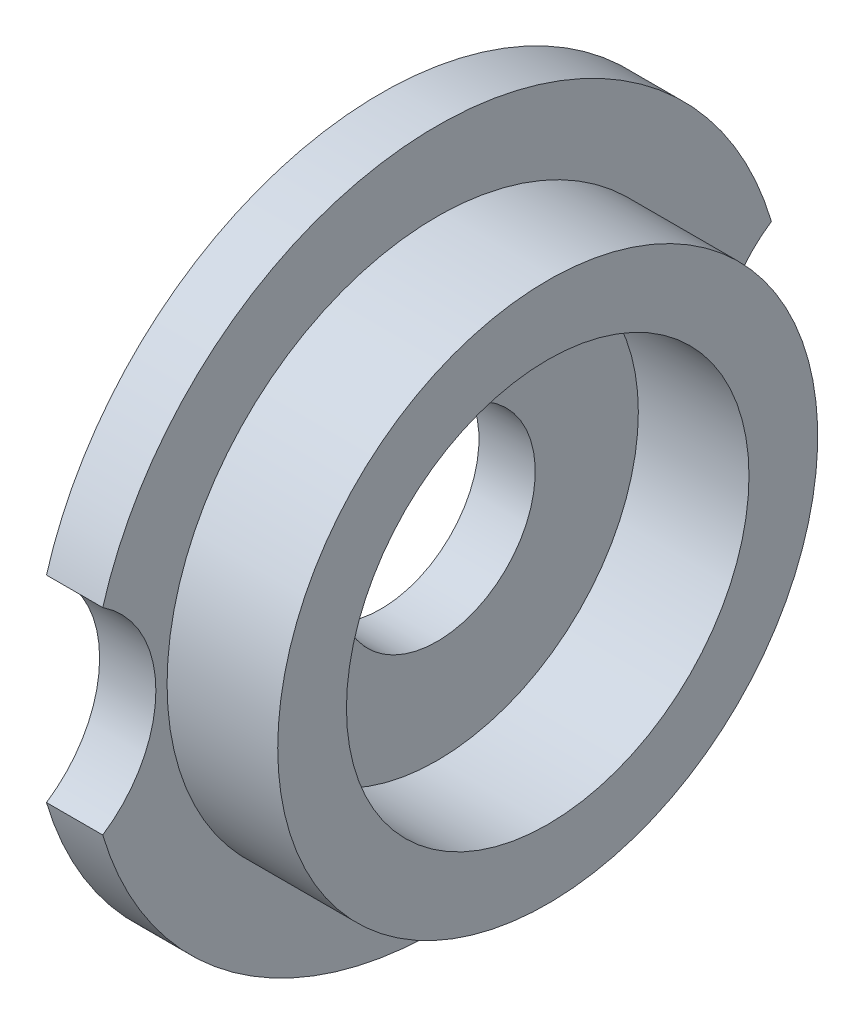
from build123d import *

# Parameters (mm, degrees)
M8_CLEARANCE_HOLE1_D     = 10
M8_CLEARANCE_HOLE1_DEPTH = 8.5
SKETCH4_R                = 6
CUT_EXTRUDE1_DEPTH       = 10


with BuildPart() as part:
    # Sketch1 → Revolve1 (revolve)
    with BuildSketch(Plane.XY):
        Polygon((-2.865, 4.25), (-2.865, 17.75), (0, 17.75), (0, 13.75), (5.635, 13.75), (5.635, 10.25), (0, 10.25), (0, 4.25), align=None)
    revolve(axis=Axis((-29.387999347, 0, 0), (1, 0, 0)))

    # M8 Clearance Hole1
    with Locations(Plane.ZY.offset(2.865)):
        with Locations((0, 0)):
            Hole(M8_CLEARANCE_HOLE1_D / 2, depth=M8_CLEARANCE_HOLE1_DEPTH)

    # Sketch4 → Cut-Extrude1 (cut)
    with BuildSketch(Plane.ZY.offset(2.865)):
        with Locations((-20.32, 0)):
            Circle(SKETCH4_R)
        with Locations((20.32, 0)):
            Circle(SKETCH4_R)
    extrude(amount=-CUT_EXTRUDE1_DEPTH, mode=Mode.SUBTRACT)


solid = part.part
